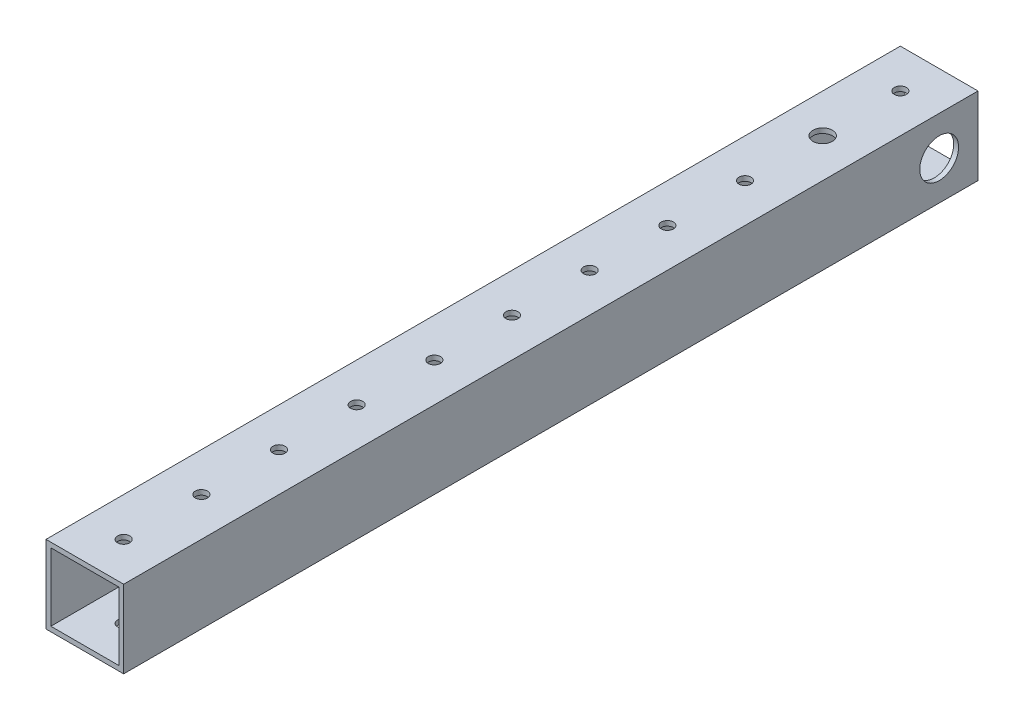
from build123d import *

# Parameters (mm, degrees)
SKETCH1_W           = 25.4
SKETCH1_H           = 25.4
SKETCH1_W_2         = 22.225
SKETCH1_H_2         = 22.225
BOSS_EXTRUDE1_DEPTH = 279.4
SKETCH2_R           = 1.984375
CUT_EXTRUDE1_DEPTH  = 26.4
SKETCH3_R           = 3.175
CUT_EXTRUDE2_DEPTH  = 26.4
SKETCH4_R           = 6.35
CUT_EXTRUDE3_DEPTH  = 26.4


with BuildPart() as part:
    # Sketch1 → Boss-Extrude1 (new body)
    with BuildSketch(Plane.XY):
        Rectangle(SKETCH1_W, SKETCH1_H)
        Rectangle(SKETCH1_W_2, SKETCH1_H_2, mode=Mode.SUBTRACT)
    extrude(amount=BOSS_EXTRUDE1_DEPTH)

    # Sketch2 → Cut-Extrude1 (cut, through all)
    with BuildSketch(Plane(origin=(0, 12.7, 0), x_dir=(1, 0, 0), z_dir=(0, 1, 0))):
        with Locations((0, -266.7)):
            Circle(SKETCH2_R)
        with Locations((0, -241.3)):
            Circle(SKETCH2_R)
        with Locations((0, -215.9)):
            Circle(SKETCH2_R)
        with Locations((0, -190.5)):
            Circle(SKETCH2_R)
        with Locations((0, -165.1)):
            Circle(SKETCH2_R)
        with Locations((0, -139.7)):
            Circle(SKETCH2_R)
        with Locations((0, -114.3)):
            Circle(SKETCH2_R)
        with Locations((0, -88.9)):
            Circle(SKETCH2_R)
        with Locations((0, -63.5)):
            Circle(SKETCH2_R)
        with Locations((0, -38.1)):
            Circle(SKETCH2_R)
        with Locations((0, -12.7)):
            Circle(SKETCH2_R)
        with Locations((0, 12.7)):
            Circle(SKETCH2_R)
    extrude(amount=-CUT_EXTRUDE1_DEPTH, mode=Mode.SUBTRACT)

    # Sketch3 → Cut-Extrude2 (cut, through all)
    with BuildSketch(Plane(origin=(0, 12.7, 0), x_dir=(1, 0, 0), z_dir=(0, 1, 0))):
        with Locations((0, -38.1)):
            Circle(SKETCH3_R)
    extrude(amount=-CUT_EXTRUDE2_DEPTH, mode=Mode.SUBTRACT)

    # Sketch4 → Cut-Extrude3 (cut, through all)
    with BuildSketch(Plane(origin=(12.7, 0, 0), x_dir=(0, 0, -1), z_dir=(1, 0, 0))):
        with Locations((-12.7, 0)):
            Circle(SKETCH4_R)
    extrude(amount=-CUT_EXTRUDE3_DEPTH, mode=Mode.SUBTRACT)


solid = part.part
